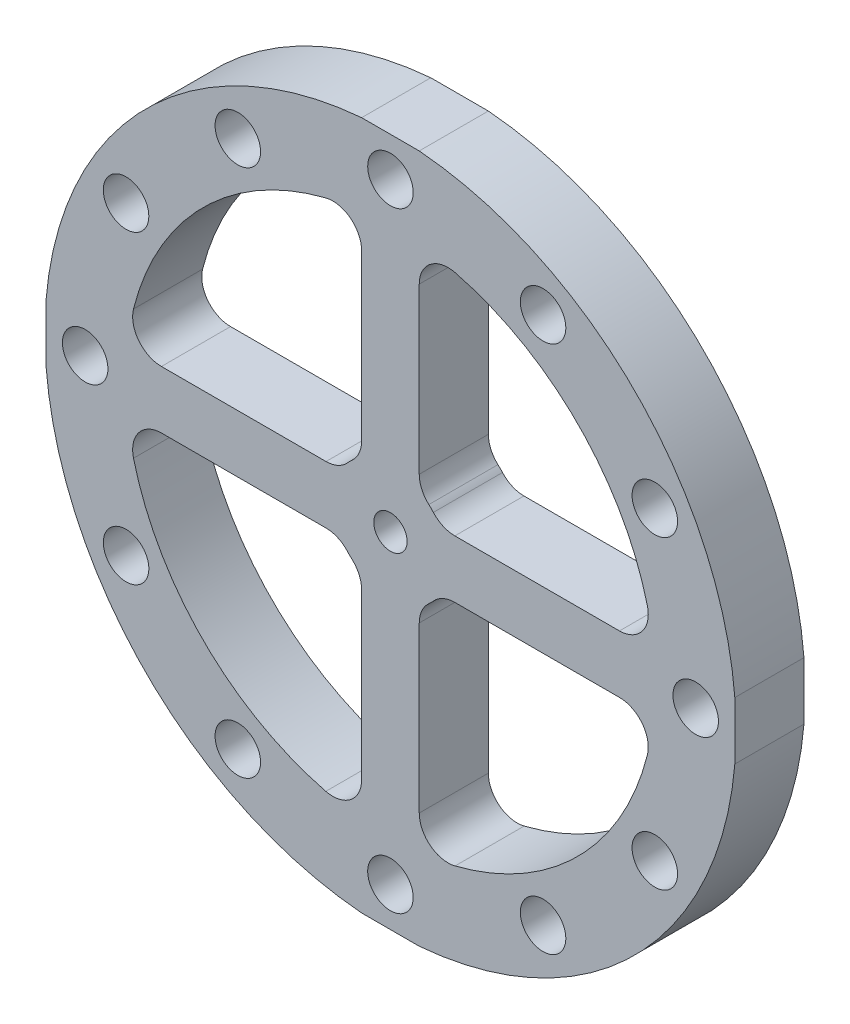
from build123d import *

# Parameters (mm, degrees)
SKIZZE1_W                       = 10
SKIZZE1_H                       = 10
SKIZZE1_R                       = 2.9
AUFSATZ_LINEAR_AUSTRAGEN3_DEPTH = 12
SKIZZE2_R                       = 3.95
SCHNITT_LINEAR_AUSTRAGEN1_DEPTH = 12
KREISMUSTER1_COUNT              = 12
VERRUNDUNG1_R                   = 5


with BuildPart() as part:
    # Skizze1 → Aufsatz-Linear austragen3 (new body)
    with BuildSketch(Plane.XY):
        with BuildLine():
            Line((-59.791303716, 5), (-59.791303716, -5))
            Line((-59.791303716, -5), (-45.727453461, -5))
            ThreePointArc((-45.727453461, -5), (-46, 0), (-45.727453461, 5))
            Line((-45.727453461, 5), (-59.791303716, 5))
        make_face()
        with BuildLine():
            ThreePointArc((-45.727453461, 5), (-46, 0), (-45.727453461, -5))
            Line((-45.727453461, -5), (-8.660254038, -5))
            ThreePointArc((-8.660254038, -5), (-10, 0), (-8.660254038, 5))
            Line((-8.660254038, 5), (-45.727453461, 5))
        make_face()
        with BuildLine():
            Line((8.660254038, -5), (45.727453461, -5))
            ThreePointArc((45.727453461, -5), (45.931812827, -2.503711326), (46, 0))
            ThreePointArc((46, 0), (45.931812827, 2.503711326), (45.727453461, 5))
            Line((45.727453461, 5), (8.660254038, 5))
            ThreePointArc((8.660254038, 5), (9.659258263, 2.588190451), (10, 0))
            ThreePointArc((10, 0), (9.659258263, -2.588190451), (8.660254038, -5))
        make_face()
        Rectangle(SKIZZE1_W, SKIZZE1_H)
        Circle(SKIZZE1_R, mode=Mode.SUBTRACT)
        with BuildLine():
            ThreePointArc((-8.660254038, 5), (-10, 0), (-8.660254038, -5))
            Line((-8.660254038, -5), (-5, -5))
            Line((-5, -5), (-5, 5))
            Line((-5, 5), (-8.660254038, 5))
        make_face()
        with BuildLine():
            ThreePointArc((-5, 8.660254038), (-7.071067812, 7.071067812), (-8.660254038, 5))
            Line((-8.660254038, 5), (-5, 5))
            Line((-5, 5), (-5, 8.660254038))
        make_face()
        with BuildLine():
            Line((-5, 8.660254038), (-5, 5))
            Line((-5, 5), (5, 5))
            Line((5, 5), (5, 8.660254038))
            ThreePointArc((5, 8.660254038), (0, 10), (-5, 8.660254038))
        make_face()
        with BuildLine():
            Line((5, 8.660254038), (5, 5))
            Line((5, 5), (8.660254038, 5))
            ThreePointArc((8.660254038, 5), (7.071067812, 7.071067812), (5, 8.660254038))
        make_face()
        with BuildLine():
            Line((5, 5), (5, -5))
            Line((5, -5), (8.660254038, -5))
            ThreePointArc((8.660254038, -5), (9.659258263, -2.588190451), (10, 0))
            ThreePointArc((10, 0), (9.659258263, 2.588190451), (8.660254038, 5))
            Line((8.660254038, 5), (5, 5))
        make_face()
        with BuildLine():
            Line((45.727453461, -5), (59.791303716, -5))
            Line((59.791303716, -5), (59.791303716, 5))
            Line((59.791303716, 5), (45.727453461, 5))
            ThreePointArc((45.727453461, 5), (45.931812827, 2.503711326), (46, 0))
            ThreePointArc((46, 0), (45.931812827, -2.503711326), (45.727453461, -5))
        make_face()
        with BuildLine():
            ThreePointArc((59.791303716, 5), (42.426406871, 42.426406871), (5, 59.791303716))
            Line((5, 59.791303716), (5, 45.727453461))
            ThreePointArc((5, 45.727453461), (32.526911935, 32.526911935), (45.727453461, 5))
            Line((45.727453461, 5), (59.791303716, 5))
        make_face()
        with BuildLine():
            Line((5, 59.791303716), (-5, 59.791303716))
            Line((-5, 59.791303716), (-5, 45.727453461))
            ThreePointArc((-5, 45.727453461), (0, 46), (5, 45.727453461))
            Line((5, 45.727453461), (5, 59.791303716))
        make_face()
        with BuildLine():
            ThreePointArc((-5, 59.791303716), (-42.426406871, 42.426406871), (-59.791303716, 5))
            Line((-59.791303716, 5), (-45.727453461, 5))
            ThreePointArc((-45.727453461, 5), (-32.526911935, 32.526911935), (-5, 45.727453461))
            Line((-5, 45.727453461), (-5, 59.791303716))
        make_face()
        with BuildLine():
            Line((-5, -8.660254038), (-5, -45.727453461))
            ThreePointArc((-5, -45.727453461), (0, -46), (5, -45.727453461))
            Line((5, -45.727453461), (5, -8.660254038))
            ThreePointArc((5, -8.660254038), (0, -10), (-5, -8.660254038))
        make_face()
        with BuildLine():
            ThreePointArc((5, 45.727453461), (0, 46), (-5, 45.727453461))
            Line((-5, 45.727453461), (-5, 8.660254038))
            ThreePointArc((-5, 8.660254038), (0, 10), (5, 8.660254038))
            Line((5, 8.660254038), (5, 45.727453461))
        make_face()
        with BuildLine():
            Line((-5, -5), (-8.660254038, -5))
            ThreePointArc((-8.660254038, -5), (-7.071067812, -7.071067812), (-5, -8.660254038))
            Line((-5, -8.660254038), (-5, -5))
        make_face()
        with BuildLine():
            Line((5, -5), (-5, -5))
            Line((-5, -5), (-5, -8.660254038))
            ThreePointArc((-5, -8.660254038), (0, -10), (5, -8.660254038))
            Line((5, -8.660254038), (5, -5))
        make_face()
        with BuildLine():
            Line((8.660254038, -5), (5, -5))
            Line((5, -5), (5, -8.660254038))
            ThreePointArc((5, -8.660254038), (7.071067812, -7.071067812), (8.660254038, -5))
        make_face()
        with BuildLine():
            Line((-45.727453461, -5), (-59.791303716, -5))
            ThreePointArc((-59.791303716, -5), (-42.426406871, -42.426406871), (-5, -59.791303716))
            Line((-5, -59.791303716), (-5, -45.727453461))
            ThreePointArc((-5, -45.727453461), (-32.526911935, -32.526911935), (-45.727453461, -5))
        make_face()
        with BuildLine():
            Line((-5, -45.727453461), (-5, -59.791303716))
            Line((-5, -59.791303716), (5, -59.791303716))
            Line((5, -59.791303716), (5, -45.727453461))
            ThreePointArc((5, -45.727453461), (0, -46), (-5, -45.727453461))
        make_face()
        with BuildLine():
            Line((5, -45.727453461), (5, -59.791303716))
            ThreePointArc((5, -59.791303716), (42.426406871, -42.426406871), (59.791303716, -5))
            Line((59.791303716, -5), (45.727453461, -5))
            ThreePointArc((45.727453461, -5), (32.526911935, -32.526911935), (5, -45.727453461))
        make_face()
    extrude(amount=AUFSATZ_LINEAR_AUSTRAGEN3_DEPTH)

    # Skizze2 → Schnitt-Linear austragen1 (cut)
    with BuildSketch(Plane.XY.offset(12)):
        with Locations((0, -53)):
            Circle(SKIZZE2_R)
    schnitt_linear_austragen1 = extrude(amount=-SCHNITT_LINEAR_AUSTRAGEN1_DEPTH, mode=Mode.SUBTRACT)

    # Kreismuster1: Schnitt-Linear austragen1 ×12 about axis
    kreismuster1_axis = Axis((0, 0, 0), (0, 0, 1))
    for i in range(1, KREISMUSTER1_COUNT):
        add(schnitt_linear_austragen1.rotate(kreismuster1_axis, i * 360 / KREISMUSTER1_COUNT), mode=Mode.SUBTRACT)

    # Verrundung1
    verrundung1_edges = [part.edges().sort_by_distance(p)[0] for p in [
        (-8.660254038, -5, 6),
        (-45.727453461, -5, 6),
        (-5, -45.727453461, 6),
        (-5, -8.660254038, 6),
        (-5, 45.727453461, 6),
        (-45.727453461, 5, 6),
        (-8.660254038, 5, 6),
        (-5, 8.660254038, 6),
        (45.727453461, 5, 6),
        (5, 45.727453461, 6),
        (5, 8.660254038, 6),
        (8.660254038, 5, 6),
        (5, -8.660254038, 6),
        (5, -45.727453461, 6),
        (45.727453461, -5, 6),
        (8.660254038, -5, 6),
    ]]
    fillet(verrundung1_edges, radius=VERRUNDUNG1_R)


solid = part.part
